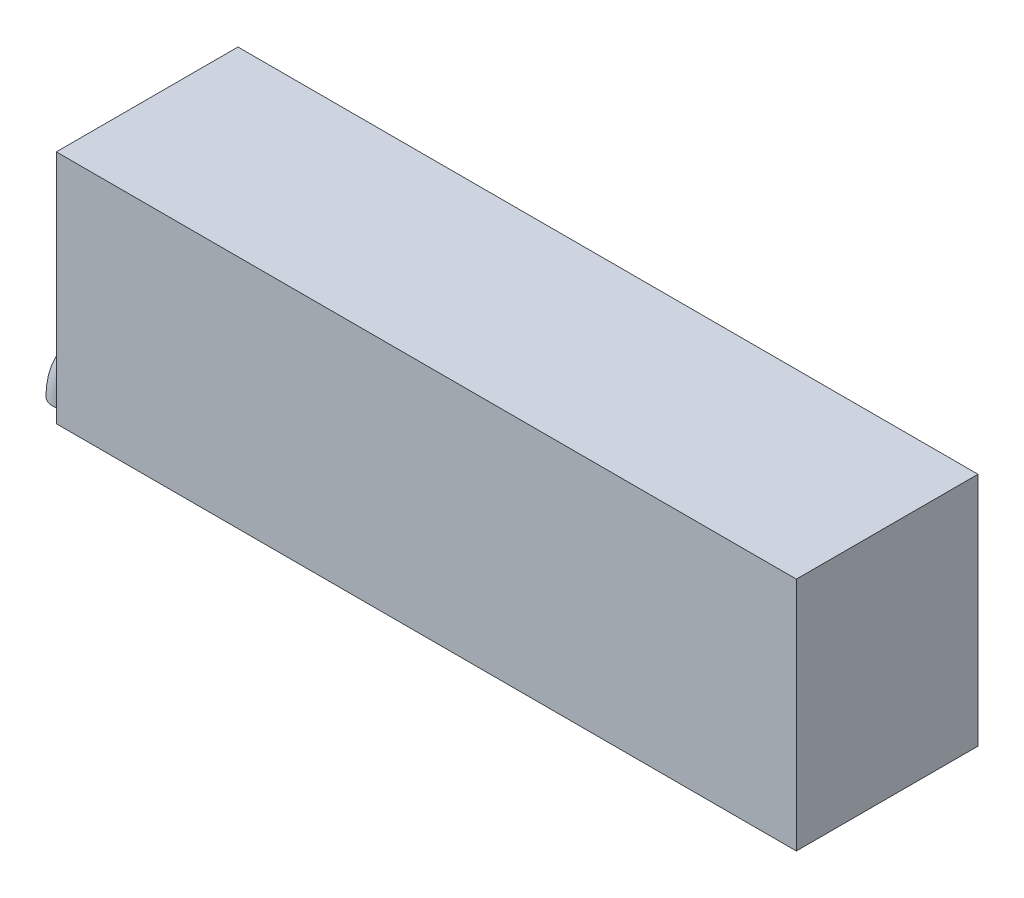
from build123d import *

# Parameters (mm, degrees)
SKETCH_1_W      = 110
SKETCH_1_H      = 35
EXTRUDE_1_DEPTH = 13.5
REVOLVE_1_ANGLE = 90


with BuildPart() as part:
    # 草圖1 → 填料-伸長1 (new body, symmetric)
    with BuildSketch(Plane.XY):
        Rectangle(SKETCH_1_W, SKETCH_1_H)
    extrude(amount=EXTRUDE_1_DEPTH, both=True)

    # 草圖2 → 旋轉1 (revolve)
    with BuildSketch(Plane.ZY.offset(55)):
        with BuildLine():
            Line((-2.5, -12.5), (2.5, -12.5))
            ThreePointArc((2.5, -12.5), (5, -15), (2.5, -17.5))
            Line((2.5, -17.5), (-2.5, -17.5))
            ThreePointArc((-2.5, -17.5), (-5, -15), (-2.5, -12.5))
        make_face()
    revolve(axis=Axis((-55, -24.005362061, -6.079544695), (0, 0, 1)), revolution_arc=REVOLVE_1_ANGLE)


solid = part.part
